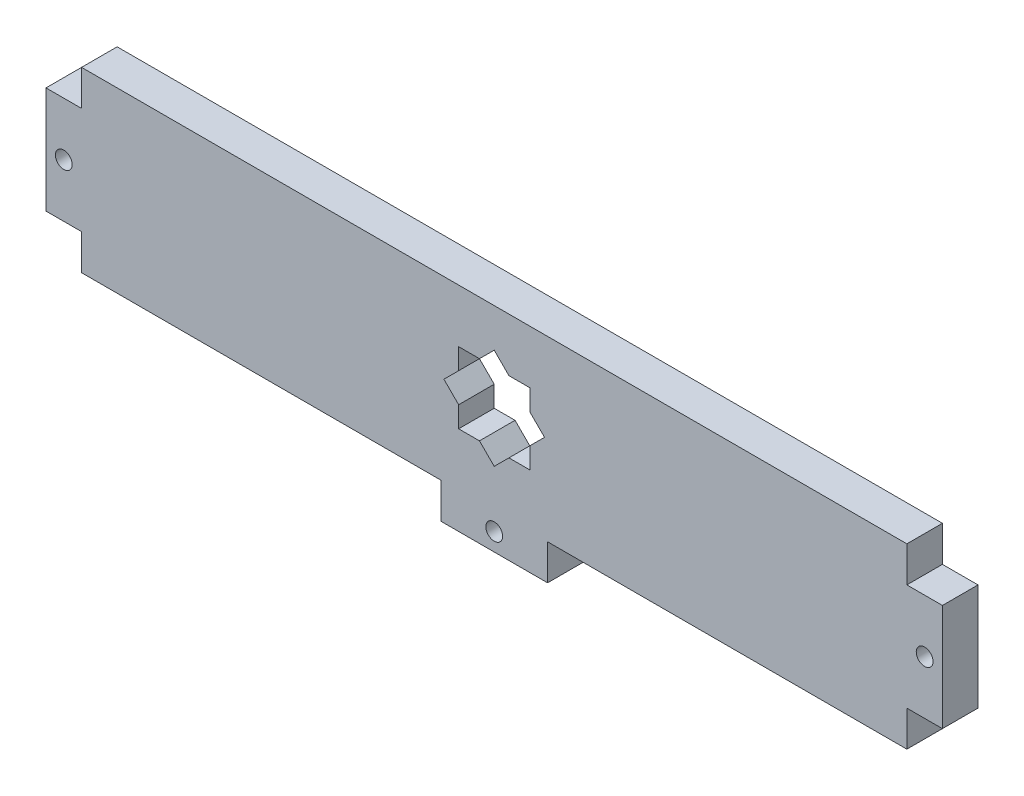
from build123d import *

# Parameters (mm, degrees)
SKETCH1_W           = 147.32
SKETCH1_H           = 31.75
BOSS_EXTRUDE1_DEPTH = 6.35
SKETCH2_W           = 6.35
SKETCH2_H           = 19.05
SKETCH2_R           = 1.5
SKETCH2_W_2         = 19.05
SKETCH2_H_2         = 6.35
BOSS_EXTRUDE2_DEPTH = 6.35
CUT_EXTRUDE1_DEPTH  = 6.35


with BuildPart() as part:
    # Sketch1 → Boss-Extrude1 (new body)
    with BuildSketch(Plane.XY):
        Rectangle(SKETCH1_W, SKETCH1_H)
    extrude(amount=-BOSS_EXTRUDE1_DEPTH)

    # Sketch2 → Boss-Extrude2 (add)
    with BuildSketch(Plane.XY):
        with Locations((76.835, 0)):
            Rectangle(SKETCH2_W, SKETCH2_H)
        with Locations((76.835, 0)):
            Circle(SKETCH2_R, mode=Mode.SUBTRACT)
        with Locations((-76.835, 0)):
            Rectangle(SKETCH2_W, SKETCH2_H)
        with Locations((-76.835, 0)):
            Circle(SKETCH2_R, mode=Mode.SUBTRACT)
        with Locations((0, -19.05)):
            Rectangle(SKETCH2_W_2, SKETCH2_H_2)
        with Locations((0, -19.05)):
            Circle(SKETCH2_R, mode=Mode.SUBTRACT)
    extrude(amount=-BOSS_EXTRUDE2_DEPTH)

    # Sketch3 → Cut-Extrude1 (cut)
    with BuildSketch(Plane.XY):
        Polygon((0, -8.980256121), (2.630256121, -6.35), (6.35, -6.35), (6.35, -2.630256121), (8.980256121, 0), (6.35, 2.630256121), (6.35, 6.35), (2.630256121, 6.35), (0, 8.980256121), (-2.630256121, 6.35), (-6.35, 6.35), (-6.35, 2.630256121), (-8.980256121, 0), (-6.35, -2.630256121), (-6.35, -6.35), (-2.630256121, -6.35), align=None)
    extrude(amount=-CUT_EXTRUDE1_DEPTH, mode=Mode.SUBTRACT)


solid = part.part
